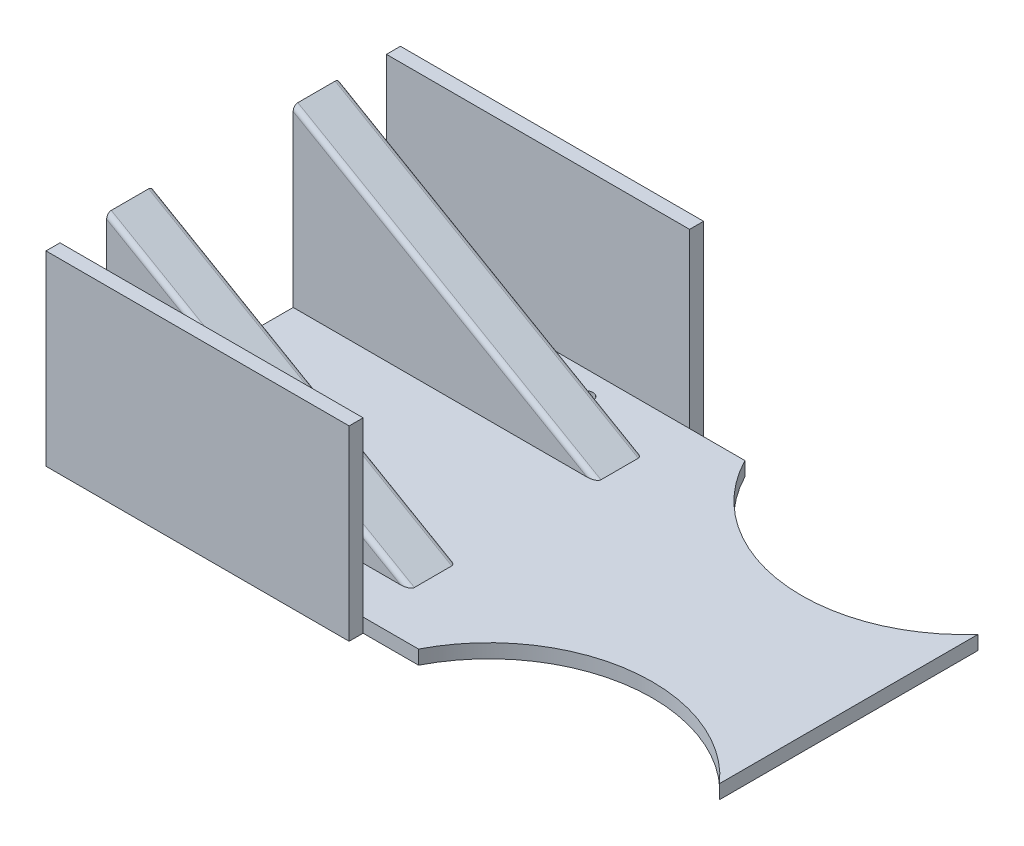
from build123d import *

# Parameters (mm, degrees)
SKETCH_1_W           = 220
SKETCH_1_H           = 70
EXTRUDE_1_DEPTH      = 3
EXTRUDE_2_DEPTH      = 25
EXTRUDE_2_DEPTH_BACK = 25
SKETCH_6_W           = 30
SKETCH_6_H           = 37.527767497
CUT_EXTRUDE_4_DEPTH  = 221
SKETCH_7_R           = 35
CUT_EXTRUDE_5_DEPTH  = 4
SKETCH_8_W           = 3
SKETCH_8_H           = 40
EXTRUDE_3_DEPTH      = 65
SKETCH_9_R           = 1.5
CUT_EXTRUDE_6_DEPTH  = 4
FILLET_5_R           = 1
SKETCH_12_R          = 1.5
CUT_EXTRUDE_8_DEPTH  = 4


with BuildPart() as part:
    # 草图1 → 凸台-拉伸1 (new body)
    with BuildSketch(Plane(origin=(0, 0, 0), x_dir=(1, 0, 0), z_dir=(0, 1, 0))):
        with Locations((27.295373665, 0)):
            Rectangle(SKETCH_1_W, SKETCH_1_H)
    extrude(amount=EXTRUDE_1_DEPTH)

    # 草图2 → 凸台-拉伸2 (add, two sides)
    with BuildSketch(Plane.XY) as extrude_2_sk:
        Polygon((-82.704626335, 40.527767497), (-82.704626335, 3), (-17.704626335, 3), align=None)
    extrude(amount=EXTRUDE_2_DEPTH)
    extrude(extrude_2_sk.sketch, amount=-EXTRUDE_2_DEPTH_BACK)

    # 草图6 → 切除-拉伸4 (cut, through all)
    with BuildSketch(Plane.ZY.offset(82.704626335)):
        with Locations((0, 21.763883748)):
            Rectangle(SKETCH_6_W, SKETCH_6_H)
    extrude(amount=-CUT_EXTRUDE_4_DEPTH, mode=Mode.SUBTRACT)

    # 草图7 → 切除-拉伸5 (cut, through all)
    with BuildSketch(Plane(origin=(0, 3, 0), x_dir=(1, 0, 0), z_dir=(0, 1, 0))):
        with Locations((25.295373665, 51)):
            Circle(SKETCH_7_R)
        with Locations((25.295373665, -51)):
            Circle(SKETCH_7_R)
    extrude(amount=-CUT_EXTRUDE_5_DEPTH, mode=Mode.SUBTRACT)

    # 草图8 → 凸台-拉伸3 (add)
    with BuildSketch(Plane.ZY.offset(82.704626335)):
        with Locations((36.5, 20)):
            Rectangle(SKETCH_8_W, SKETCH_8_H)
        with Locations((-36.5, 20)):
            Rectangle(SKETCH_8_W, SKETCH_8_H)
    extrude(amount=-EXTRUDE_3_DEPTH)

    # 草图9 → 切除-拉伸6 (cut, through all)
    with BuildSketch(Plane(origin=(0, 3, 0), x_dir=(1, 0, 0), z_dir=(0, 1, 0))):
        with Locations((-74.766784803, 29.860059225)):
            Circle(SKETCH_9_R)
        with Locations((-54.766784803, 29.860059225)):
            Circle(SKETCH_9_R)
        with Locations((-34.766784803, 29.860059225)):
            Circle(SKETCH_9_R)
        with Locations((-34.766784803, -29.860059225)):
            Circle(SKETCH_9_R)
        with Locations((-54.766784803, -29.860059225)):
            Circle(SKETCH_9_R)
        with Locations((-74.766784803, -29.860059225)):
            Circle(SKETCH_9_R)
        with Locations((68.031562246, 22)):
            Circle(SKETCH_9_R)
        with Locations((88.031562246, 22)):
            Circle(SKETCH_9_R)
        with Locations((108.031562246, 22)):
            Circle(SKETCH_9_R)
        with Locations((108.031562246, -22)):
            Circle(SKETCH_9_R)
        with Locations((88.031562246, -22)):
            Circle(SKETCH_9_R)
        with Locations((68.031562246, -22)):
            Circle(SKETCH_9_R)
        with Locations((128.031562246, 22)):
            Circle(SKETCH_9_R)
        with Locations((128.031562246, -22)):
            Circle(SKETCH_9_R)
    extrude(amount=-CUT_EXTRUDE_6_DEPTH, mode=Mode.SUBTRACT)

    # 圆角5
    fillet_5_edges = [part.edges().sort_by_distance(p)[0] for p in [
        (-50.204626335, 21.763883749, -25),
        (-50.204626335, 21.763883749, 25),
        (-50.204626335, 21.763883749, -15),
        (-50.204626335, 21.763883749, 15),
    ]]
    fillet(fillet_5_edges, radius=FILLET_5_R)

    # 草图12 → 切除-拉伸8 (cut, through all)
    with BuildSketch(Plane(origin=(0, 3, 0), x_dir=(1, 0, 0), z_dir=(0, 1, 0))):
        with BuildLine():
            Line((51.424138498, 27.712929589), (51.424138498, 0))
            Line((51.424138498, 0), (51.424138498, -27.712929589))
            ThreePointArc((51.424138498, -27.712929589), (54.155060508, -31.198018398), (56.424138498, -35))
            Line((56.424138498, -35), (137.295373665, -35))
            Line((137.295373665, -35), (137.295373665, 35))
            Line((137.295373665, 35), (56.424138498, 35))
            ThreePointArc((56.424138498, 35), (54.155060508, 31.198018398), (51.424138498, 27.712929589))
        make_face()
        with Locations((68.031562246, -22)):
            Circle(SKETCH_12_R, mode=Mode.SUBTRACT)
        with Locations((88.031562246, -22)):
            Circle(SKETCH_12_R, mode=Mode.SUBTRACT)
        with Locations((108.031562246, -22)):
            Circle(SKETCH_12_R, mode=Mode.SUBTRACT)
        with Locations((128.031562246, -22)):
            Circle(SKETCH_12_R, mode=Mode.SUBTRACT)
        with Locations((68.031562246, 22)):
            Circle(SKETCH_12_R, mode=Mode.SUBTRACT)
        with Locations((88.031562246, 22)):
            Circle(SKETCH_12_R, mode=Mode.SUBTRACT)
        with Locations((108.031562246, 22)):
            Circle(SKETCH_12_R, mode=Mode.SUBTRACT)
        with Locations((128.031562246, 22)):
            Circle(SKETCH_12_R, mode=Mode.SUBTRACT)
    extrude(amount=-CUT_EXTRUDE_8_DEPTH, mode=Mode.SUBTRACT)


solid = part.part
